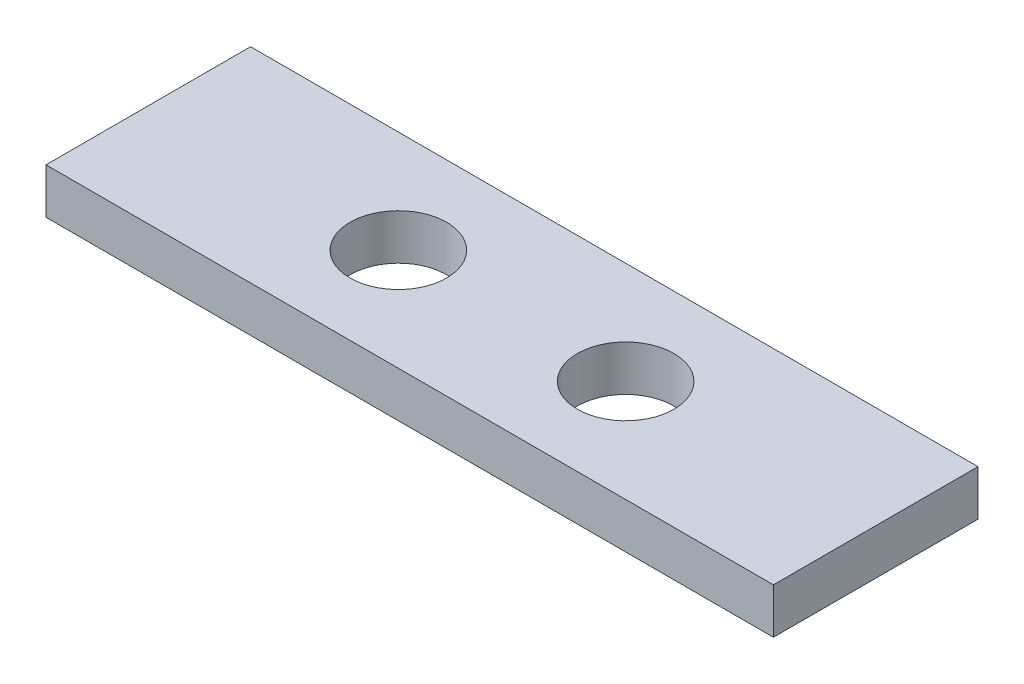
from build123d import *

# Parameters (mm, degrees)
SKETCH1_W               = 28.575
SKETCH1_H               = 6.35
EXTRUDE1_DEPTH          = 50.8
EXTRUDE1_DEPTH_BACK     = 50.8
F_1_2_CLEARANCE_HOLE1_D = 13.49248


with BuildPart() as part:
    # Sketch1 → Extrude1 (new body, two sides)
    with BuildSketch(Plane(origin=(0, 0, 0), x_dir=(0, 0, -1), z_dir=(1, 0, 0))) as extrude1_sk:
        Rectangle(SKETCH1_W, SKETCH1_H)
    extrude(amount=EXTRUDE1_DEPTH)
    extrude(extrude1_sk.sketch, amount=-EXTRUDE1_DEPTH_BACK)

    # 1_2 Clearance Hole1 (through all)
    with Locations(Plane(origin=(0, 3.175, 0), x_dir=(-1, 0, 0), z_dir=(0, 1, 0))):
        with Locations((15.875, 0), (-15.875, 0)):
            Hole(F_1_2_CLEARANCE_HOLE1_D / 2)


solid = part.part
